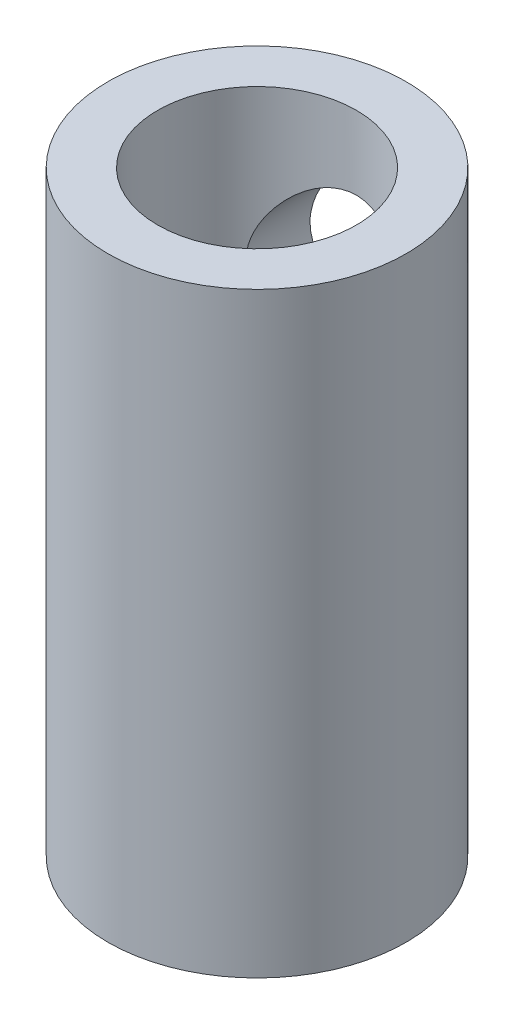
from build123d import *

# Parameters (mm, degrees)
SKETCH1_R           = 4.7625
BOSS_EXTRUDE1_DEPTH = 19.05
SKETCH2_R           = 3
CUT_EXTRUDE1_DEPTH  = 9.525
SKETCH3_R           = 3.175
CUT_EXTRUDE2_DEPTH  = 9.525
CUT_EXTRUDE3_REACH  = 11.525
SKETCH4_R           = 2.413


with BuildPart() as part:
    # Sketch1 → Boss-Extrude1 (new body)
    with BuildSketch(Plane(origin=(0, 0, 0), x_dir=(1, 0, 0), z_dir=(0, 1, 0))):
        Circle(SKETCH1_R)
    extrude(amount=BOSS_EXTRUDE1_DEPTH)

    # Sketch2 → Cut-Extrude1 (cut)
    with BuildSketch(Plane.XZ):
        Circle(SKETCH2_R)
    extrude(amount=-CUT_EXTRUDE1_DEPTH, mode=Mode.SUBTRACT)

    # Sketch3 → Cut-Extrude2 (cut)
    with BuildSketch(Plane(origin=(0, 19.05, 0), x_dir=(1, 0, 0), z_dir=(0, 1, 0))):
        Circle(SKETCH3_R)
    extrude(amount=-CUT_EXTRUDE2_DEPTH, mode=Mode.SUBTRACT)

    # Sketch4 → Cut-Extrude3 (cut, up to next)
    with BuildSketch(Plane(origin=(0, 0, -4.7625), x_dir=(-1, 0, 0), z_dir=(0, 0, -1)), mode=Mode.PRIVATE) as cut_extrude3_sk1:
        with Locations((0, 14.2875)):
            Circle(SKETCH4_R)
    cut_extrude3_tool1 = extrude(cut_extrude3_sk1.sketch, amount=-CUT_EXTRUDE3_REACH, mode=Mode.PRIVATE) & part.part
    add(cut_extrude3_tool1.solids().sort_by_distance((0, 14.2875, -4.7625))[0], mode=Mode.SUBTRACT)
    # Sketch4 → Cut-Extrude3 (cut, up to next)
    with BuildSketch(Plane(origin=(0, 0, -4.7625), x_dir=(-1, 0, 0), z_dir=(0, 0, -1)), mode=Mode.PRIVATE) as cut_extrude3_sk2:
        with Locations((0, 4.7625)):
            Circle(SKETCH4_R)
    cut_extrude3_tool2 = extrude(cut_extrude3_sk2.sketch, amount=-CUT_EXTRUDE3_REACH, mode=Mode.PRIVATE) & part.part
    add(cut_extrude3_tool2.solids().sort_by_distance((0, 4.7625, -4.7625))[0], mode=Mode.SUBTRACT)


solid = part.part
